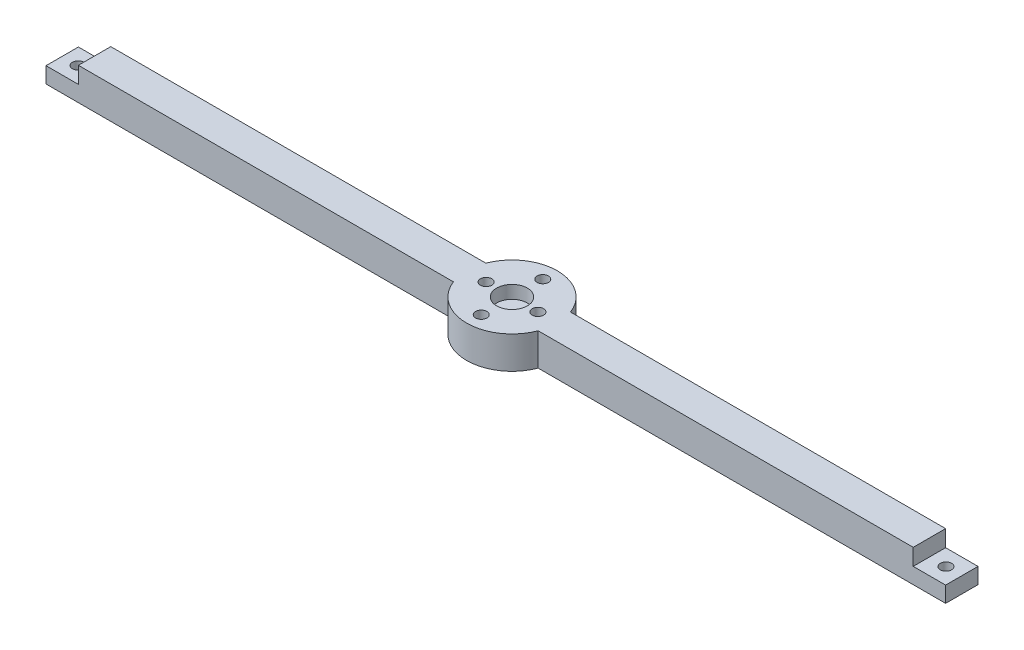
from build123d import *

# Parameters (mm, degrees)
SKETCH1_R           = 14
BOSS_EXTRUDE1_DEPTH = 10
BOSS_EXTRUDE2_DEPTH = 10
CUT_EXTRUDE2_DEPTH  = 20
SKETCH6_R           = 1.75
CUT_EXTRUDE4_DEPTH  = 10
CIRPATTERN2_COUNT   = 2
CIRPATTERN2_ANGLE   = 180
SKETCH5_R           = 1.75
CUT_EXTRUDE3_DEPTH  = 11
SKETCH7_R           = 4.75
CUT_EXTRUDE5_DEPTH  = 4


with BuildPart() as part:
    # Sketch1 → Boss-Extrude1 (new body)
    with BuildSketch(Plane(origin=(0, 0, 0), x_dir=(1, 0, 0), z_dir=(0, 1, 0))):
        Circle(SKETCH1_R)
    extrude(amount=BOSS_EXTRUDE1_DEPTH)

    # Sketch2 → Boss-Extrude2 (add)
    with BuildSketch(Plane(origin=(0, 10, 0), x_dir=(1, 0, 0), z_dir=(0, 1, 0))):
        with BuildLine():
            Line((13.076696831, -5), (149, -5))
            Line((149, -5), (149, 5))
            Line((149, 5), (13.076696831, 5))
            ThreePointArc((13.076696831, 5), (14, 0), (13.076696831, -5))
        make_face()
    boss_extrude2 = extrude(amount=-BOSS_EXTRUDE2_DEPTH)

    # Sketch4 → Cut-Extrude2 (cut, through all)
    with BuildSketch(Plane.XY.offset(5)):
        Polygon((138.9, 0), (138.9, 4.9), (128.9, 4.9), (128.9, 10), (149, 10), (149, 0), align=None)
    cut_extrude2 = extrude(amount=-CUT_EXTRUDE2_DEPTH, mode=Mode.SUBTRACT)

    # Sketch6 → Cut-Extrude4 (cut)
    with BuildSketch(Plane(origin=(0, 4.9, 0), x_dir=(1, 0, 0), z_dir=(0, 1, 0))):
        with Locations((134, 0)):
            Circle(SKETCH6_R)
    cut_extrude4 = extrude(amount=-CUT_EXTRUDE4_DEPTH, mode=Mode.SUBTRACT)

    # CirPattern2: Boss-Extrude2, Cut-Extrude2, Cut-Extrude4 ×2 about axis
    cirpattern2_axis = Axis((0, 0, 0), (0, 1, 0))
    for i in range(1, CIRPATTERN2_COUNT):
        add(boss_extrude2.rotate(cirpattern2_axis, i * CIRPATTERN2_ANGLE / (CIRPATTERN2_COUNT - 1)))
        add(cut_extrude2.rotate(cirpattern2_axis, i * CIRPATTERN2_ANGLE / (CIRPATTERN2_COUNT - 1)), mode=Mode.SUBTRACT)
        add(cut_extrude4.rotate(cirpattern2_axis, i * CIRPATTERN2_ANGLE / (CIRPATTERN2_COUNT - 1)), mode=Mode.SUBTRACT)

    # Sketch5 → Cut-Extrude3 (cut, through all)
    with BuildSketch(Plane(origin=(0, 10, 0), x_dir=(1, 0, 0), z_dir=(0, 1, 0))):
        with Locations((0, 9.5)):
            Circle(SKETCH5_R)
        with Locations((8, 0)):
            Circle(SKETCH5_R)
        with Locations((-8, 0)):
            Circle(SKETCH5_R)
        with Locations((0, -9.5)):
            Circle(SKETCH5_R)
    extrude(amount=-CUT_EXTRUDE3_DEPTH, mode=Mode.SUBTRACT)

    # Sketch7 → Cut-Extrude5 (cut)
    with BuildSketch(Plane(origin=(0, 10, 0), x_dir=(1, 0, 0), z_dir=(0, 1, 0))):
        Circle(SKETCH7_R)
    extrude(amount=-CUT_EXTRUDE5_DEPTH, mode=Mode.SUBTRACT)


solid = part.part
